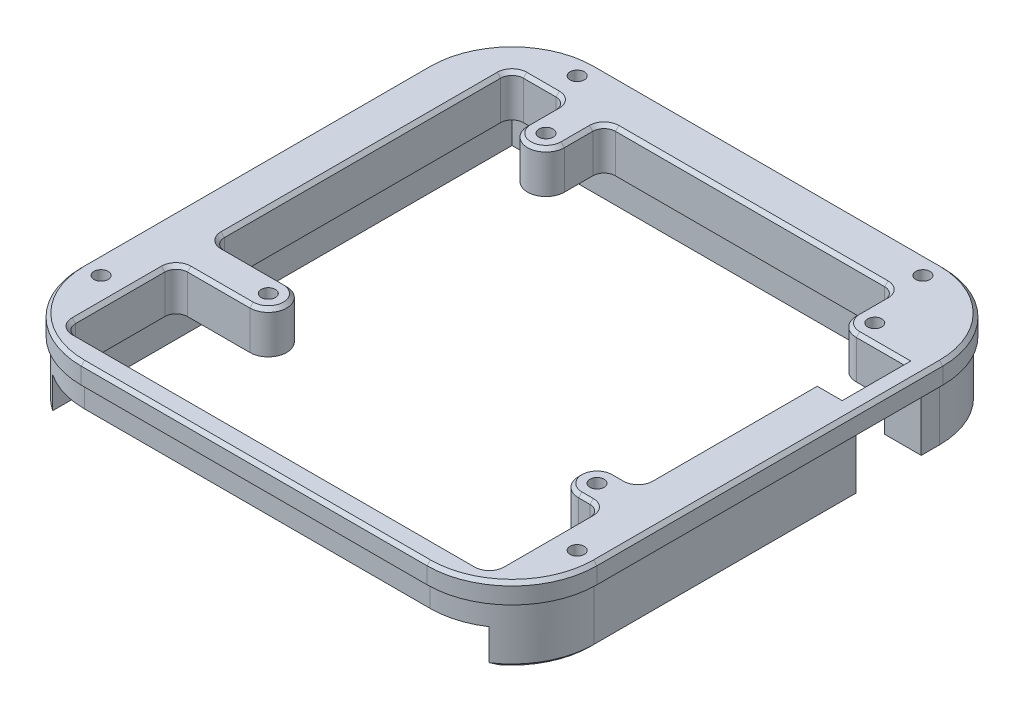
from build123d import *

# Parameters (mm, degrees)
SKETCH1_W                   = 91
SKETCH1_H                   = 91
SKETCH1_R                   = 1.25
BOSS_EXTRUDE1_DEPTH         = 7.4
SKETCH3_W                   = 5
SKETCH3_H                   = 11.5
CUT_EXTRUDE1_DEPTH          = 8.4
SKETCH4_W                   = 91
SKETCH4_H                   = 91
BOSS_EXTRUDE2_DEPTH         = 6.1
FILLET1_R                   = 15
CUT_EXTRUDE2_DEPTH          = 10
SKETCH9_W                   = 11.5
SKETCH9_H                   = 10
CUT_EXTRUDE3_DEPTH          = 10
CUT_EXTRUDE4_DEPTH          = 6.1
FILLET2_R                   = 2
TAP_DRILL_FOR_M3X0_5_TAP1_D = 2.5
CHAMFER1_SIZE               = 0.6


with BuildPart() as part:
    # Sketch1 → Boss-Extrude1 (new body)
    with BuildSketch(Plane(origin=(0, 0, 0), x_dir=(1, 0, 0), z_dir=(0, 1, 0))):
        with Locations((-1.280392157, -3.837254902)):
            Rectangle(SKETCH1_W, SKETCH1_H)
        with BuildLine():
            Line((28.969607843, 33.662745098), (28.969607843, 26.662745098))
            ThreePointArc((28.969607843, 26.662745098), (29.921510804, 24.364648059), (32.219607843, 23.412745098))
            Line((32.219607843, 23.412745098), (36.219607843, 23.412745098))
            Line((36.219607843, 23.412745098), (36.219607843, -19.087254902))
            Line((36.219607843, -19.087254902), (32.219607843, -19.087254902))
            ThreePointArc((32.219607843, -19.087254902), (28.969607843, -22.337254902), (32.219607843, -25.587254902))
            Line((32.219607843, -25.587254902), (36.219607843, -25.587254902))
            Line((36.219607843, -25.587254902), (36.219607843, -45.337254902))
            Line((36.219607843, -45.337254902), (-38.780392157, -45.337254902))
            Line((-38.780392157, -45.337254902), (-38.780392157, -25.587254902))
            Line((-38.780392157, -25.587254902), (-25.780392157, -25.587254902))
            ThreePointArc((-25.780392157, -25.587254902), (-22.530392157, -22.337254902), (-25.780392157, -19.087254902))
            Line((-25.780392157, -19.087254902), (-38.780392157, -19.087254902))
            Line((-38.780392157, -19.087254902), (-38.780392157, 33.662745098))
            Line((-38.780392157, 33.662745098), (-29.030392157, 33.662745098))
            Line((-29.030392157, 33.662745098), (-29.030392157, 26.662745098))
            ThreePointArc((-29.030392157, 26.662745098), (-25.780392157, 23.412745098), (-22.530392157, 26.662745098))
            Line((-22.530392157, 26.662745098), (-22.530392157, 33.662745098))
            Line((-22.530392157, 33.662745098), (28.969607843, 33.662745098))
        make_face(mode=Mode.SUBTRACT)
        with Locations((32.219607843, 26.662745098)):
            Circle(SKETCH1_R, mode=Mode.SUBTRACT)
        with Locations((-25.780392157, 26.662745098)):
            Circle(SKETCH1_R, mode=Mode.SUBTRACT)
        with Locations((32.219607843, -22.337254902)):
            Circle(SKETCH1_R, mode=Mode.SUBTRACT)
        with Locations((-25.780392157, -22.337254902)):
            Circle(SKETCH1_R, mode=Mode.SUBTRACT)
    extrude(amount=BOSS_EXTRUDE1_DEPTH)

    # Sketch3 → Cut-Extrude1 (cut, through all)
    with BuildSketch(Plane.XZ):
        with Locations((38.719607843, -17.662745098)):
            Rectangle(SKETCH3_W, SKETCH3_H)
    extrude(amount=-CUT_EXTRUDE1_DEPTH, mode=Mode.SUBTRACT)

    # Sketch4 → Boss-Extrude2 (add)
    with BuildSketch(Plane.XZ):
        with Locations((-1.280392157, 3.837254902)):
            Rectangle(SKETCH4_W, SKETCH4_H)
        Polygon((37.219607843, 45.337254902), (37.219607843, -11.912745098), (41.219607843, -11.912745098), (41.219607843, -23.412745098), (37.219607843, -23.412745098), (37.219607843, -33.662745098), (37.219607843, -34.662745098), (36.219607843, -34.662745098), (-39.780392157, -34.662745098), (-39.780392157, 25.587254902), (-39.780392157, 45.337254902), (-39.780392157, 46.337254902), (-38.780392157, 46.337254902), (36.219607843, 46.337254902), (37.219607843, 46.337254902), align=None, mode=Mode.SUBTRACT)
    extrude(amount=BOSS_EXTRUDE2_DEPTH)

    # Fillet1
    fillet1_edges = [part.edges().sort_by_distance(p)[0] for p in [
        (-46.780392157, 0.65, 49.337254902),
        (-46.780392157, 0.65, -41.662745098),
        (44.219607843, 0.65, -41.662745098),
        (44.219607843, 0.65, 49.337254902),
    ]]
    fillet(fillet1_edges, radius=FILLET1_R)

    # Sketch8 → Cut-Extrude2 (cut)
    with BuildSketch(Plane.XZ.offset(6.1)):
        with BuildLine():
            Line((29.219607843, 49.337254902), (-31.780392157, 49.337254902))
            ThreePointArc((-31.780392157, 49.337254902), (-42.386993875, 44.94385662), (-46.780392157, 34.337254902))
            Line((-46.780392157, 34.337254902), (-46.780392157, -26.662745098))
            ThreePointArc((-46.780392157, -26.662745098), (-42.386993875, -37.269346816), (-31.780392157, -41.662745098))
            Line((-31.780392157, -41.662745098), (29.219607843, -41.662745098))
            ThreePointArc((29.219607843, -41.662745098), (39.826209561, -37.269346816), (44.219607843, -26.662745098))
            Line((44.219607843, -26.662745098), (44.219607843, 34.337254902))
            ThreePointArc((44.219607843, 34.337254902), (39.826209561, 44.94385662), (29.219607843, 49.337254902))
        make_face()
        with BuildLine():
            Line((29.219607843, 48.787254902), (-31.780392157, 48.787254902))
            ThreePointArc((-31.780392157, 48.787254902), (-41.998085145, 44.55494789), (-46.230392157, 34.337254902))
            Line((-46.230392157, 34.337254902), (-46.230392157, -26.662745098))
            ThreePointArc((-46.230392157, -26.662745098), (-41.998085145, -36.880438086), (-31.780392157, -41.112745098))
            Line((-31.780392157, -41.112745098), (29.219607843, -41.112745098))
            ThreePointArc((29.219607843, -41.112745098), (39.437300831, -36.880438086), (43.669607843, -26.662745098))
            Line((43.669607843, -26.662745098), (43.669607843, 34.337254902))
            ThreePointArc((43.669607843, 34.337254902), (39.437300831, 44.55494789), (29.219607843, 48.787254902))
        make_face(mode=Mode.SUBTRACT)
    extrude(amount=-CUT_EXTRUDE2_DEPTH, mode=Mode.SUBTRACT)

    # Sketch9 → Cut-Extrude3 (cut)
    with BuildSketch(Plane(origin=(43.669607843, 0, 0), x_dir=(0, 0, -1), z_dir=(1, 0, 0))):
        with Locations((17.662745098, -1.1)):
            Rectangle(SKETCH9_W, SKETCH9_H)
    extrude(amount=-CUT_EXTRUDE3_DEPTH, mode=Mode.SUBTRACT)

    # Sketch10 → Cut-Extrude4 (cut)
    with BuildSketch(Plane.XZ.offset(6.1)):
        with BuildLine():
            Line((-39.780392157, 46.337254902), (37.219607843, 46.337254902))
            Line((37.219607843, 46.337254902), (37.219607843, 46.370645945))
            ThreePointArc((37.219607843, 46.370645945), (33.398124292, 48.169915539), (29.219607843, 48.787254902))
            Line((29.219607843, 48.787254902), (-31.780392157, 48.787254902))
            ThreePointArc((-31.780392157, 48.787254902), (-35.958908606, 48.169915539), (-39.780392157, 46.370645945))
            Line((-39.780392157, 46.370645945), (-39.780392157, 46.337254902))
        make_face()
    extrude(amount=-CUT_EXTRUDE4_DEPTH, mode=Mode.SUBTRACT)

    # Fillet2
    fillet2_edges = [part.edges().sort_by_distance(p)[0] for p in [
        (-29.030392157, 3.7, -33.662745098),
        (-38.780392157, 3.7, -33.662745098),
        (-38.780392157, 3.7, 19.087254902),
        (-38.780392157, 3.7, 25.587254902),
        (-38.780392157, 3.7, 45.337254902),
        (36.219607843, 3.7, 45.337254902),
        (36.219607843, 3.7, 25.587254902),
        (36.219607843, 3.7, 19.087254902),
        (28.969607843, 3.7, -33.662745098),
        (-22.530392157, 3.7, -33.662745098),
    ]]
    fillet(fillet2_edges, radius=FILLET2_R)

    # Tap Drill for M3x0.5 Tap1 (through all)
    with Locations(Plane(origin=(-31.780392157, 7.4, -38.162745098), x_dir=(0, 0, 1), z_dir=(0, 1, 0))):
        with Locations((0, 0), (0, 61), (72.5, -11.5), (72.5, 72.5)):
            Hole(TAP_DRILL_FOR_M3X0_5_TAP1_D / 2)

    # Chamfer1
    chamfer1_edges = [part.edges().sort_by_distance(p)[0] for p in [
        (-29.030392157, 7.4, -29.162745098),
        (37.219607843, -6.1, 17.228950424),
        (37.219607843, -6.1, -29.037745098),
        (40.444607843, -6.1, -11.912745098),
        (40.444607843, -6.1, -23.412745098),
        (-1.280392157, -6.1, -34.662745098),
        (-39.780392157, -6.1, 5.853950424),
        (-1.280392157, 7.4, 49.337254902),
        (-46.780392157, 7.4, 3.837254902),
        (44.219607843, 7.4, 3.837254902),
        (-1.280392157, 7.4, -41.662745098),
        (-42.386993875, 7.4, -37.269346816),
        (39.826209561, 7.4, -37.269346816),
        (39.826209561, 7.4, 44.94385662),
        (-42.386993875, 7.4, 44.94385662),
        (-25.780392157, 7.4, -23.412745098),
        (41.955433297, -6.1, 41.163765724),
        (43.669607843, -6.1, -25.037745098),
        (39.437300831, -6.1, -36.880438086),
        (-1.280392157, -6.1, -41.112745098),
        (-41.998085145, -6.1, -36.880438086),
        (-46.230392157, -6.1, 3.837254902),
        (-22.530392157, 7.4, -29.162745098),
        (43.669607843, -6.1, 11.212254902),
        (-44.516217611, -6.1, 41.163765724),
        (-38.780392157, 7.4, -7.287745098),
        (-38.780392157, 7.4, 35.462254902),
        (36.219607843, 7.4, 35.462254902),
        (-33.905392157, 7.4, -33.662745098),
        (3.219607843, 7.4, -33.662745098),
        (-1.280392157, 7.4, 45.337254902),
        (-38.194605719, 7.4, 18.501468464),
        (-38.194605719, 7.4, 26.17304134),
        (35.633821406, 7.4, 26.17304134),
        (28.969607843, 7.4, -29.162745098),
        (35.633821406, 7.4, 18.501468464),
        (-38.194605719, 7.4, -33.07695866),
        (-29.616178594, 7.4, -33.07695866),
        (-21.944605719, 7.4, -33.07695866),
        (28.383821406, 7.4, -33.07695866),
        (-38.194605719, 7.4, 44.751468464),
        (35.633821406, 7.4, 44.751468464),
        (29.921510804, 7.4, -24.364648059),
        (36.719607843, 7.4, -23.412745098),
        (33.219607843, 7.4, 19.087254902),
        (28.969607843, 7.4, 22.337254902),
        (33.219607843, 7.4, 25.587254902),
        (-31.280392157, 7.4, 25.587254902),
        (-22.530392157, 7.4, 22.337254902),
        (36.219607843, 7.4, 2.587254902),
        (-31.280392157, 7.4, 19.087254902),
    ]]
    chamfer(chamfer1_edges, length=CHAMFER1_SIZE)


solid = part.part
